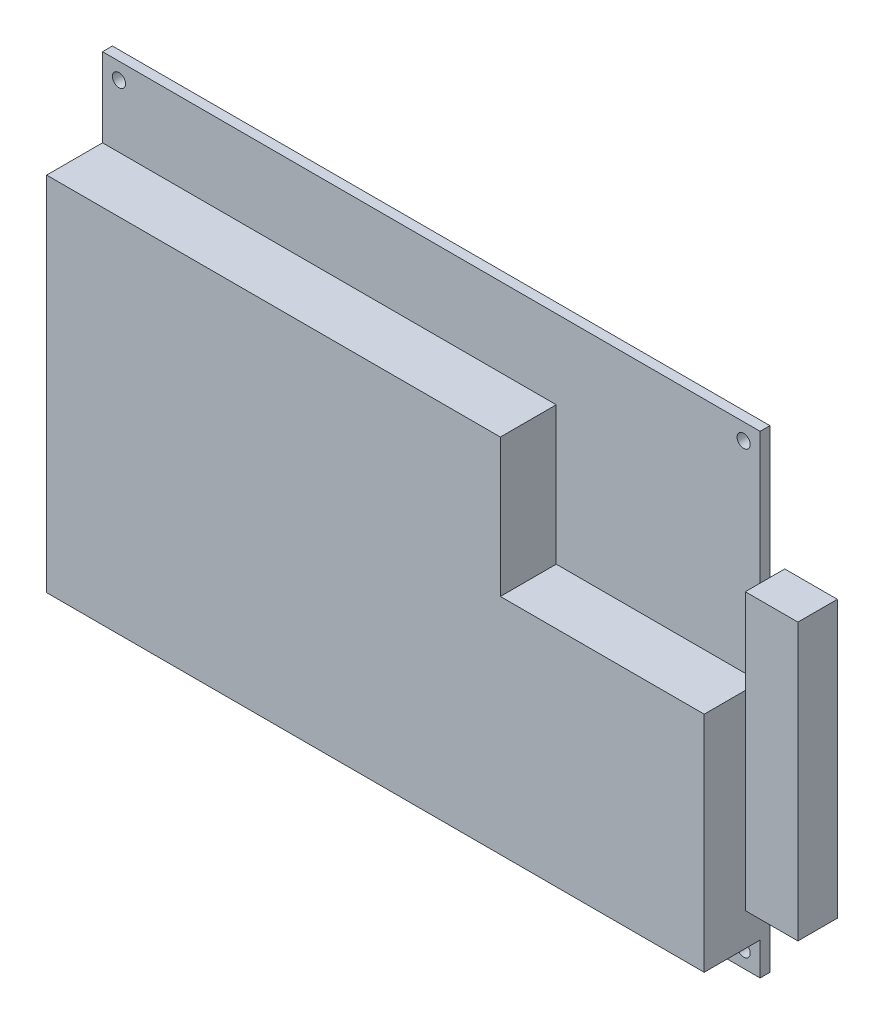
from build123d import *

# Parameters (mm, degrees)
MAIN_W                        = 100
MAIN_H                        = 72
MAIN_R                        = 1
MAIN_EXTRUSION_DEPTH          = 1.5
BOTTOM_HOLE_DEPTH             = 8.5
IDE_CONNECTOR_SKETCH_W        = 6
IDE_CONNECTOR_SKETCH_H        = 42
IDE_CONNECTOR_EXTRUSION_DEPTH = 8


with BuildPart() as part:
    # Main → Main-Extrusion (new body)
    with BuildSketch(Plane.XY):
        with Locations((50, 36)):
            Rectangle(MAIN_W, MAIN_H)
        with Locations((2.5, 69.5)):
            Circle(MAIN_R, mode=Mode.SUBTRACT)
        with Locations((2.5, 2.5)):
            Circle(MAIN_R, mode=Mode.SUBTRACT)
        with Locations((97.5, 69.5)):
            Circle(MAIN_R, mode=Mode.SUBTRACT)
        with Locations((97.5, 2.5)):
            Circle(MAIN_R, mode=Mode.SUBTRACT)
    extrude(amount=MAIN_EXTRUSION_DEPTH)

    # Bottom-Hole-Sketch → Bottom-Hole (add)
    with BuildSketch(Plane.XY.offset(1.5)):
        Polygon((0, 60), (69, 60), (69, 39), (100, 39), (100, 5), (69, 5), (0, 5), align=None)
    extrude(amount=BOTTOM_HOLE_DEPTH)

    # Ide-Connector-Sketch → Ide-Connector-Extrusion (add)
    with BuildSketch(Plane(origin=(100, 0, 0), x_dir=(0, 0, -1), z_dir=(1, 0, 0))):
        with Locations((-0.75, 31)):
            Rectangle(IDE_CONNECTOR_SKETCH_W, IDE_CONNECTOR_SKETCH_H)
    extrude(amount=IDE_CONNECTOR_EXTRUSION_DEPTH)


solid = part.part
